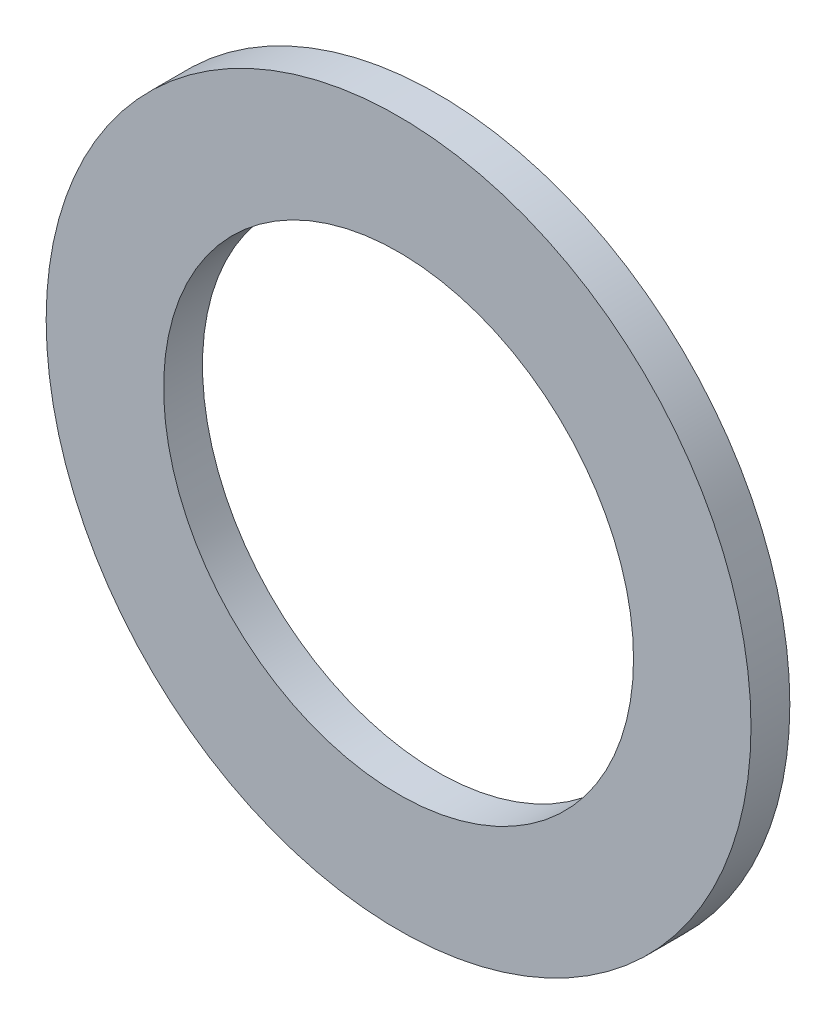
from build123d import *

# Parameters (mm, degrees)
SKETCH1_R           = 14.2875
SKETCH1_R_2         = 9.525
BOSS_EXTRUDE1_DEPTH = 1.5748


with BuildPart() as part:
    # Sketch1 → Boss-Extrude1 (new body)
    with BuildSketch(Plane.XY):
        Circle(SKETCH1_R)
        Circle(SKETCH1_R_2, mode=Mode.SUBTRACT)
    extrude(amount=BOSS_EXTRUDE1_DEPTH)


solid = part.part
